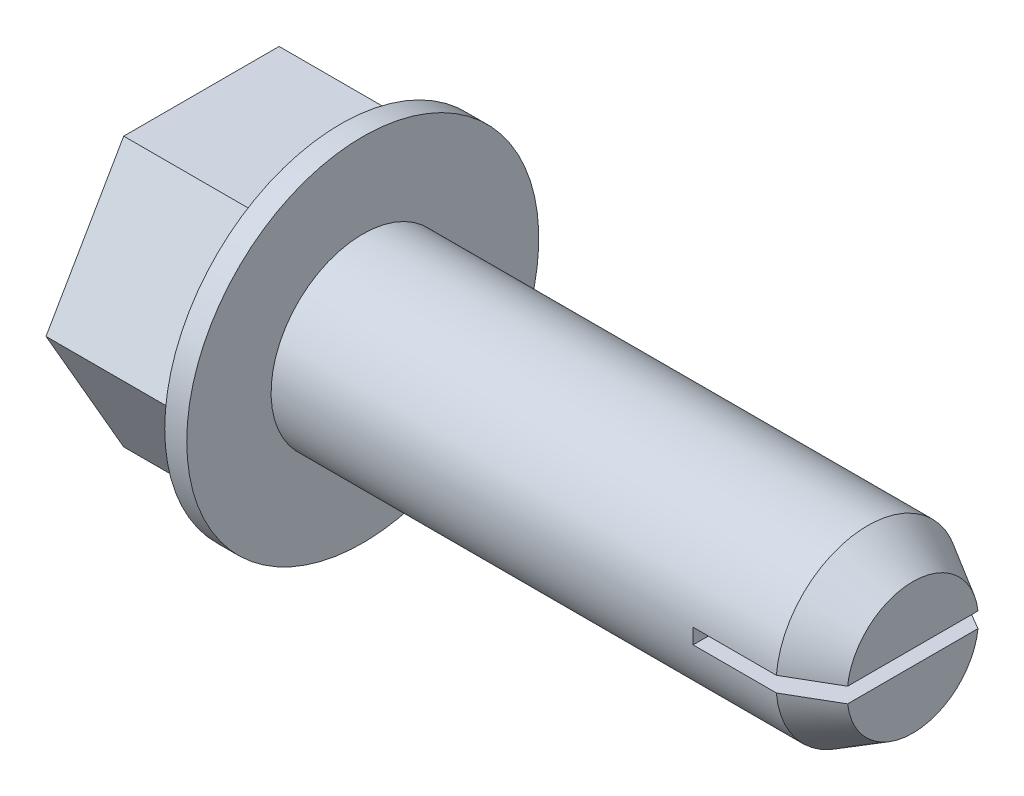
from build123d import *

# Parameters (mm, degrees)
SKETCH1_W                  = 0.762
SKETCH1_H                  = 6.096
SKETCH2_R                  = 3.175
BOSS_EXTRUDE1_DEPTH        = 19.05
CUT_EXTRUDE1_DEPTH         = 4.445
BOSS_EXTRUDE2_DEPTH        = 4.445
BOSS_EXTRUDE3_DEPTH        = 4.826
M6_5_CLEARANCE_HOLE1_D     = 7.45744
M6_5_CLEARANCE_HOLE1_DEPTH = 0.9652
CHAMFER1_SIZE              = 0.9017
CHAMFER1_SIZE2             = 1.561790213
CHAMFER1_PART_2_SIZE       = 0.9017
CHAMFER1_PART_2_SIZE2      = 1.561790213


with BuildPart() as part:
    # Sketch1 → Revolve1 (revolve)
    with BuildSketch(Plane(origin=(0, 0, 0), x_dir=(-1, 0, 0), z_dir=(0, 0, -1))):
        with Locations((0.381, 3.048)):
            Rectangle(SKETCH1_W, SKETCH1_H)
    revolve(axis=Axis((0, 0, 0), (-1, 0, 0)))

    # Sketch2 → Boss-Extrude1 (add)
    with BuildSketch(Plane(origin=(0, 0, 0), x_dir=(0, 0, -1), z_dir=(1, 0, 0))):
        Circle(SKETCH2_R)
    extrude(amount=BOSS_EXTRUDE1_DEPTH)

    # Sketch3 → Cut-Extrude1 (cut)
    with BuildSketch(Plane(origin=(19.05, 0, 0), x_dir=(0, 0, -1), z_dir=(1, 0, 0))):
        with BuildLine():
            Line((-3.163956488, -0.264583333), (3.163956488, -0.264583333))
            ThreePointArc((3.163956488, -0.264583333), (0, 3.175), (-3.163956488, -0.264583333))
        make_face()
    extrude(amount=-CUT_EXTRUDE1_DEPTH, mode=Mode.SUBTRACT)

    # Sketch4 → Boss-Extrude2 (add)
    with BuildSketch(Plane(origin=(14.605, 0, 0), x_dir=(0, 0, -1), z_dir=(1, 0, 0))):
        with BuildLine():
            Line((3.163956488, 0.264583333), (-3.163956488, 0.264583333))
            ThreePointArc((-3.163956488, 0.264583333), (0, 3.175), (3.163956488, 0.264583333))
        make_face()
    extrude(amount=BOSS_EXTRUDE2_DEPTH)

    # Sketch5 → Boss-Extrude3 (add)
    with BuildSketch(Plane.ZY.offset(0.762)):
        Polygon((-2.69097187, -4.6609), (-5.381943739, 0), (-2.69097187, 4.6609), (2.69097187, 4.6609), (5.381943739, 0), (2.69097187, -4.6609), align=None)
    extrude(amount=BOSS_EXTRUDE3_DEPTH)

    # M6.5 Clearance Hole1
    with Locations(Plane.ZY.offset(5.588)):
        with Locations((0, 0)):
            Hole(M6_5_CLEARANCE_HOLE1_D / 2, depth=M6_5_CLEARANCE_HOLE1_DEPTH)

    # Chamfer1
    chamfer1_edges = [part.edges().sort_by_distance(p)[0] for p in [
        (19.05, 3.175, 0),
    ]]
    chamfer1_side = [part.faces().sort_by_distance(p)[0] for p in [
        (19.05, 1.491577602, 0),
    ]]
    chamfer(chamfer1_edges, length=CHAMFER1_SIZE, length2=CHAMFER1_SIZE2, reference=chamfer1_side[0])

    # Chamfer1 part 2
    chamfer1_part_2_edges = [part.edges().sort_by_distance(p)[0] for p in [
        (19.05, -3.175, 0),
    ]]
    chamfer1_part_2_side = [part.faces().sort_by_distance(p)[0] for p in [
        (19.05, -1.491577602, 0),
    ]]
    chamfer(chamfer1_part_2_edges, length=CHAMFER1_PART_2_SIZE, length2=CHAMFER1_PART_2_SIZE2, reference=chamfer1_part_2_side[0])


solid = part.part
